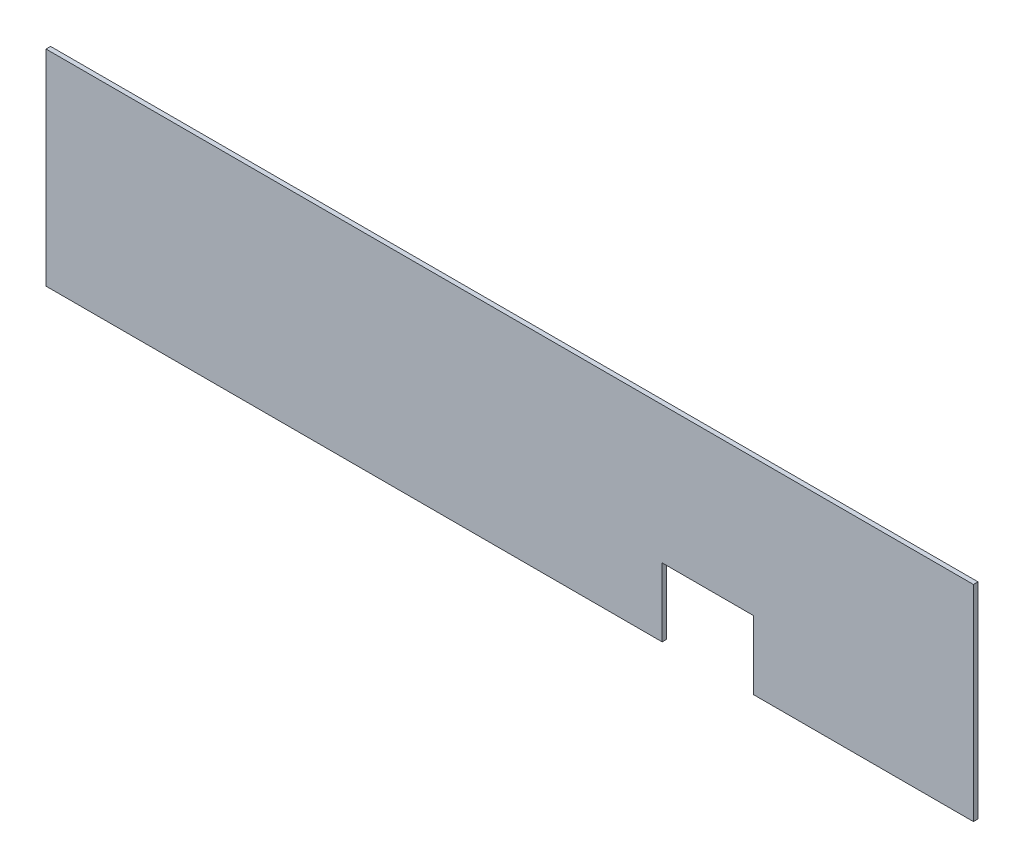
from build123d import *

# Parameters (mm, degrees)
SKETCH1_W           = 203.2
SKETCH1_H           = 45
BOSS_EXTRUDE1_DEPTH = 1
SKETCH2_W           = 20
SKETCH2_H           = 15
CUT_EXTRUDE1_DEPTH  = 1


with BuildPart() as part:
    # Sketch1 → Boss-Extrude1 (new body)
    with BuildSketch(Plane.XY):
        Rectangle(SKETCH1_W, SKETCH1_H)
    extrude(amount=BOSS_EXTRUDE1_DEPTH)

    # Sketch2 → Cut-Extrude1 (cut)
    with BuildSketch(Plane.XY.offset(1)):
        with Locations((43.4, -15)):
            Rectangle(SKETCH2_W, SKETCH2_H)
    extrude(amount=-CUT_EXTRUDE1_DEPTH, mode=Mode.SUBTRACT)


solid = part.part
